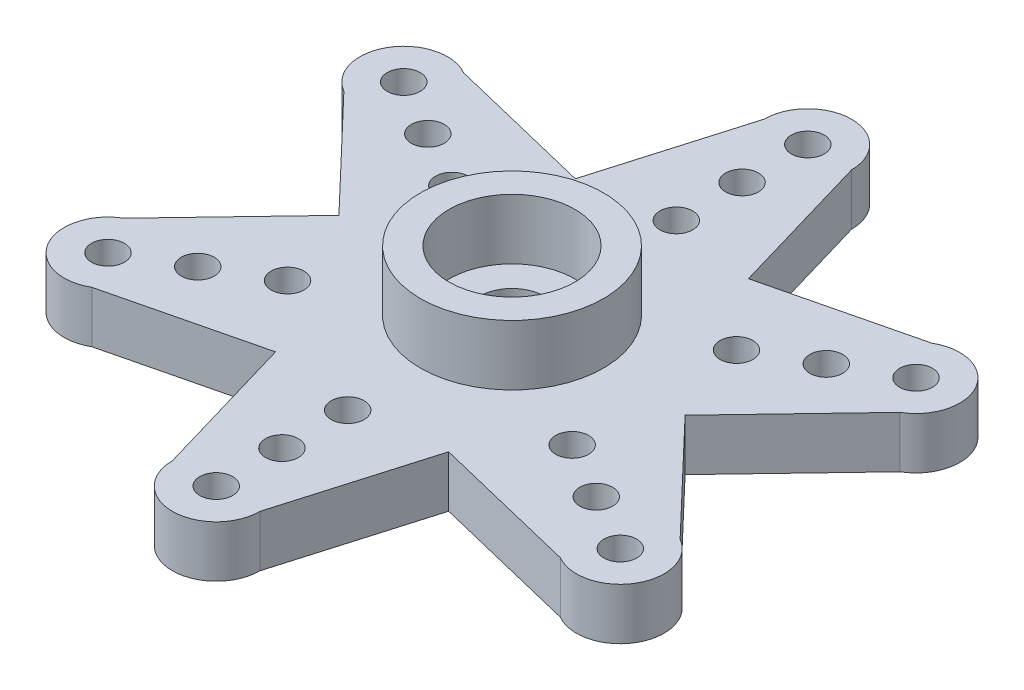
from build123d import *

# Parameters (mm, degrees)
SKETCH1_R           = 0.75
BOSS_EXTRUDE1_DEPTH = 2.35
SKETCH2_R           = 1.5
CUT_EXTRUDE1_DEPTH  = 2.35
SKETCH3_R           = 4.18
SKETCH3_R_2         = 2.875
BOSS_EXTRUDE2_DEPTH = 2.75


with BuildPart() as part:
    # Sketch1 → Boss-Extrude1 (new body)
    with BuildSketch(Plane(origin=(0, 0, 0), x_dir=(1, 0, 0), z_dir=(0, 1, 0))):
        with BuildLine():
            Line((3.95, 6.84160069), (10.691342951, 8.482050808))
            ThreePointArc((10.691342951, 8.482050808), (13.423393759, 7.75), (12.691342951, 5.017949192))
            Line((12.691342951, 5.017949192), (7.9, 0))
            Line((7.9, 0), (12.691342951, -5.017949192))
            ThreePointArc((12.691342951, -5.017949192), (13.423393759, -7.75), (10.691342951, -8.482050808))
            Line((10.691342951, -8.482050808), (3.95, -6.84160069))
            Line((3.95, -6.84160069), (2, -13.5))
            ThreePointArc((2, -13.5), (0, -15.5), (-2, -13.5))
            Line((-2, -13.5), (-3.95, -6.84160069))
            Line((-3.95, -6.84160069), (-10.691342951, -8.482050808))
            ThreePointArc((-10.691342951, -8.482050808), (-13.423393759, -7.75), (-12.691342951, -5.017949192))
            Line((-12.691342951, -5.017949192), (-7.9, 0))
            Line((-7.9, 0), (-12.691342951, 5.017949192))
            ThreePointArc((-12.691342951, 5.017949192), (-13.423393759, 7.75), (-10.691342951, 8.482050808))
            Line((-10.691342951, 8.482050808), (-3.95, 6.84160069))
            Line((-3.95, 6.84160069), (-2, 13.5))
            ThreePointArc((-2, 13.5), (0, 15.5), (2, 13.5))
            Line((2, 13.5), (3.95, 6.84160069))
        make_face()
        with Locations((0, 10.5)):
            Circle(SKETCH1_R, mode=Mode.SUBTRACT)
        with Locations((0, 13.5)):
            Circle(SKETCH1_R, mode=Mode.SUBTRACT)
        with Locations((0, 7.5)):
            Circle(SKETCH1_R, mode=Mode.SUBTRACT)
        with Locations((11.691342951, 6.75)):
            Circle(SKETCH1_R, mode=Mode.SUBTRACT)
        with Locations((9.09326674, 5.25)):
            Circle(SKETCH1_R, mode=Mode.SUBTRACT)
        with Locations((6.495190528, 3.75)):
            Circle(SKETCH1_R, mode=Mode.SUBTRACT)
        with Locations((11.691342951, -6.75)):
            Circle(SKETCH1_R, mode=Mode.SUBTRACT)
        with Locations((9.09326674, -5.25)):
            Circle(SKETCH1_R, mode=Mode.SUBTRACT)
        with Locations((6.495190528, -3.75)):
            Circle(SKETCH1_R, mode=Mode.SUBTRACT)
        with Locations((0, -13.5)):
            Circle(SKETCH1_R, mode=Mode.SUBTRACT)
        with Locations((0, -10.5)):
            Circle(SKETCH1_R, mode=Mode.SUBTRACT)
        with Locations((0, -7.5)):
            Circle(SKETCH1_R, mode=Mode.SUBTRACT)
        with Locations((-11.691342951, -6.75)):
            Circle(SKETCH1_R, mode=Mode.SUBTRACT)
        with Locations((-9.09326674, -5.25)):
            Circle(SKETCH1_R, mode=Mode.SUBTRACT)
        with Locations((-6.495190528, -3.75)):
            Circle(SKETCH1_R, mode=Mode.SUBTRACT)
        with Locations((-11.691342951, 6.75)):
            Circle(SKETCH1_R, mode=Mode.SUBTRACT)
        with Locations((-9.09326674, 5.25)):
            Circle(SKETCH1_R, mode=Mode.SUBTRACT)
        with Locations((-6.495190528, 3.75)):
            Circle(SKETCH1_R, mode=Mode.SUBTRACT)
    extrude(amount=BOSS_EXTRUDE1_DEPTH)

    # Sketch2 → Cut-Extrude1 (cut)
    with BuildSketch(Plane(origin=(0, 2.35, 0), x_dir=(1, 0, 0), z_dir=(0, 1, 0))):
        Circle(SKETCH2_R)
    extrude(amount=-CUT_EXTRUDE1_DEPTH, mode=Mode.SUBTRACT)

    # Sketch3 → Boss-Extrude2 (add)
    with BuildSketch(Plane(origin=(0, 2.35, 0), x_dir=(1, 0, 0), z_dir=(0, 1, 0))):
        Circle(SKETCH3_R)
        Circle(SKETCH3_R_2, mode=Mode.SUBTRACT)
    extrude(amount=BOSS_EXTRUDE2_DEPTH)


solid = part.part
